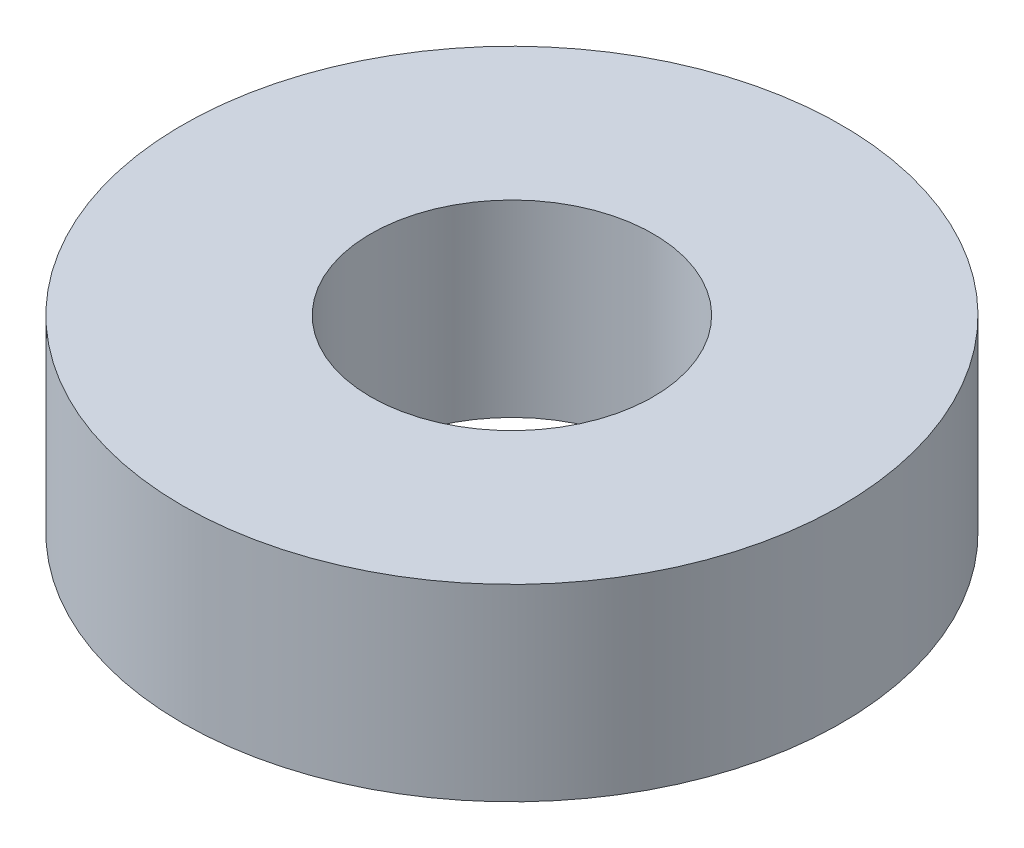
from build123d import *

# Parameters (mm, degrees)
SKETCH1_R           = 0.875
SKETCH1_R_2         = 0.375
BOSS_EXTRUDE2_DEPTH = 0.5


with BuildPart() as part:
    # Sketch1 → Boss-Extrude2 (new body)
    with BuildSketch(Plane(origin=(0, 0, 0), x_dir=(1, 0, 0), z_dir=(0, 1, 0))):
        Circle(SKETCH1_R)
        Circle(SKETCH1_R_2, mode=Mode.SUBTRACT)
    extrude(amount=BOSS_EXTRUDE2_DEPTH)


solid = part.part
